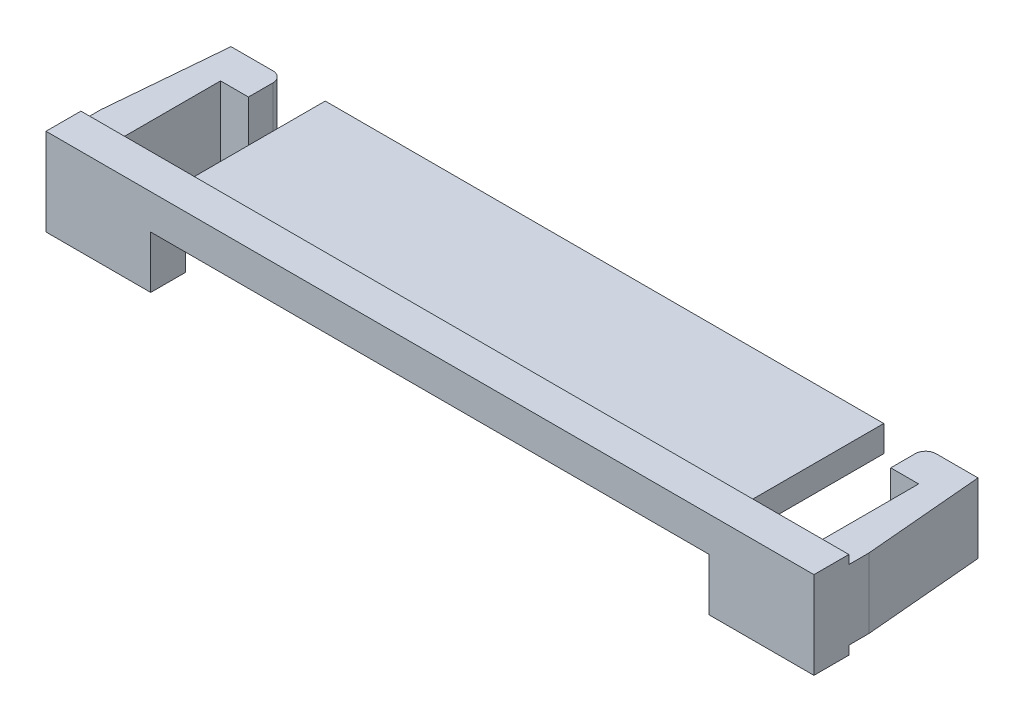
from build123d import *

# Parameters (mm, degrees)
SKETCH1_W             = 22
SKETCH1_H             = 2.5
BOSS_EXTRUDE1_DEPTH   = 5
SKETCH2_W             = 22
SKETCH2_H             = 0.25
CUT_EXTRUDE1_DEPTH    = 4
SKETCH3_W             = 2
SKETCH3_H             = 2
CUT_EXTRUDE2_DEPTH    = 4
SKETCH5_W             = 16
SKETCH5_H             = 1.5
CUT_EXTRUDE3_DEPTH    = 5
SKETCH6_W             = 1.8
SKETCH6_H             = 1
BOSS_EXTRUDE2_DEPTH   = 2
FILLET1_R             = 0.3
CHAMFER1_SIZE2        = 0.3
CHAMFER1_SIZE         = 3.429015691
CHAMFER1_EDGE_2_SIZE2 = 0.3
CHAMFER1_EDGE_2_SIZE  = 3.429015691


with BuildPart() as part:
    # Sketch1 → Boss-Extrude1 (new body)
    with BuildSketch(Plane.XY):
        Rectangle(SKETCH1_W, SKETCH1_H)
    extrude(amount=BOSS_EXTRUDE1_DEPTH)

    # Sketch2 → Cut-Extrude1 (cut)
    with BuildSketch(Plane(origin=(0, 0, 0), x_dir=(-1, 0, 0), z_dir=(0, 0, -1))):
        with Locations((0, 1.125)):
            Rectangle(SKETCH2_W, SKETCH2_H)
        with Locations((0, -1.125)):
            Rectangle(SKETCH2_W, SKETCH2_H)
    extrude(amount=-CUT_EXTRUDE1_DEPTH, mode=Mode.SUBTRACT)

    # Sketch3 → Cut-Extrude2 (cut)
    with BuildSketch(Plane(origin=(0, 0, 0), x_dir=(-1, 0, 0), z_dir=(0, 0, -1))):
        with Locations((-9, 0)):
            Rectangle(SKETCH3_W, SKETCH3_H)
        with Locations((9, 0)):
            Rectangle(SKETCH3_W, SKETCH3_H)
    extrude(amount=-CUT_EXTRUDE2_DEPTH, mode=Mode.SUBTRACT)

    # Sketch5 → Cut-Extrude3 (cut)
    with BuildSketch(Plane(origin=(0, 0, 0), x_dir=(-1, 0, 0), z_dir=(0, 0, -1))):
        with Locations((0, -0.5)):
            Rectangle(SKETCH5_W, SKETCH5_H)
    extrude(amount=-CUT_EXTRUDE3_DEPTH, mode=Mode.SUBTRACT)

    # Sketch6 → Boss-Extrude2 (add)
    with BuildSketch(Plane(origin=(0, 1, 0), x_dir=(1, 0, 0), z_dir=(0, 1, 0))):
        with Locations((-10.1, -0.5)):
            Rectangle(SKETCH6_W, SKETCH6_H)
        with Locations((10.1, -0.5)):
            Rectangle(SKETCH6_W, SKETCH6_H)
    extrude(amount=-BOSS_EXTRUDE2_DEPTH)

    # Fillet1
    fillet1_edges = [part.edges().sort_by_distance(p)[0] for p in [
        (-9.2, 0, 0),
        (9.2, 0, 0),
    ]]
    fillet(fillet1_edges, radius=FILLET1_R)

    # Chamfer1
    chamfer1_edges = [part.edges().sort_by_distance(p)[0] for p in [
        (11, 0, 0),
    ]]
    chamfer(chamfer1_edges, length=CHAMFER1_SIZE, length2=CHAMFER1_SIZE2)

    # Chamfer1 edge 2
    chamfer1_edge_2_edges = [part.edges().sort_by_distance(p)[0] for p in [
        (-11, 0, 0),
    ]]
    chamfer(chamfer1_edge_2_edges, length=CHAMFER1_EDGE_2_SIZE, length2=CHAMFER1_EDGE_2_SIZE2)


solid = part.part
